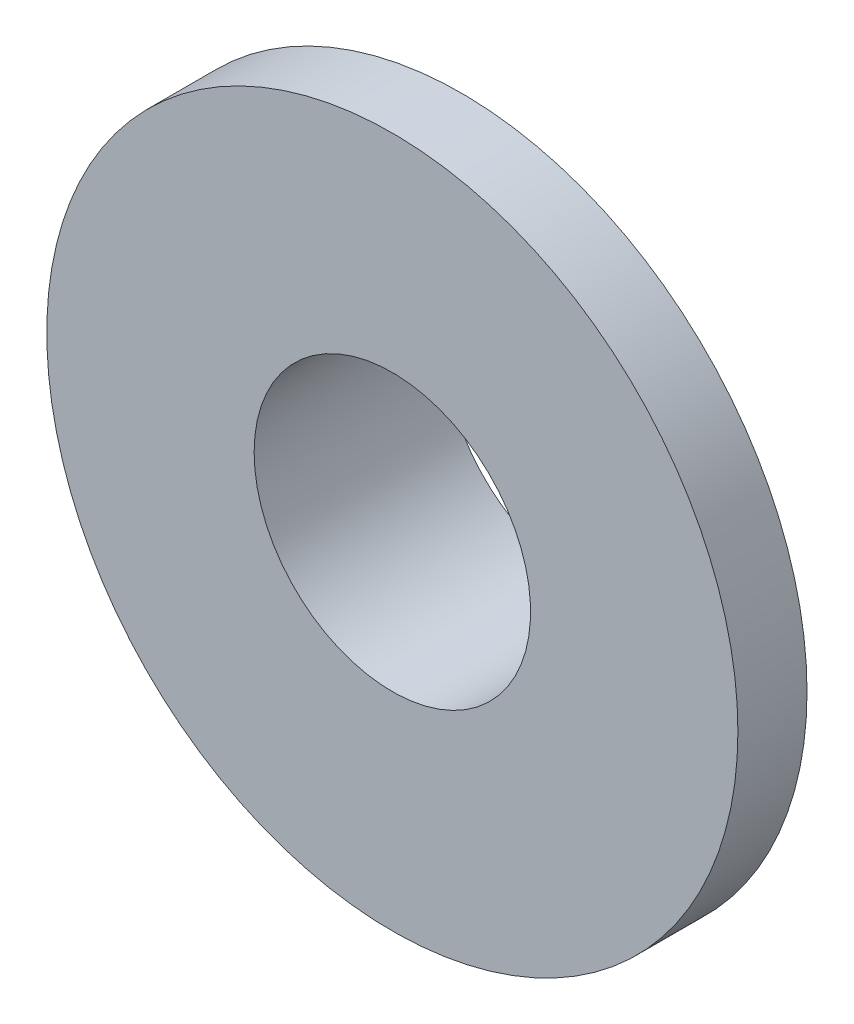
from build123d import *

# Parameters (mm, degrees)
SKETCH1_R           = 10
BOSS_EXTRUDE1_DEPTH = 2
SKETCH2_R           = 4.5
BOSS_EXTRUDE2_DEPTH = 3.5
SKETCH3_R           = 4
CUT_EXTRUDE1_DEPTH  = 6.5


with BuildPart() as part:
    # Sketch1 → Boss-Extrude1 (new body)
    with BuildSketch(Plane.XY):
        Circle(SKETCH1_R)
    extrude(amount=BOSS_EXTRUDE1_DEPTH)

    # Sketch2 → Boss-Extrude2 (add)
    with BuildSketch(Plane(origin=(0, 0, 0), x_dir=(-1, 0, 0), z_dir=(0, 0, -1))):
        Circle(SKETCH2_R)
    extrude(amount=BOSS_EXTRUDE2_DEPTH)

    # Sketch3 → Cut-Extrude1 (cut, through all)
    with BuildSketch(Plane(origin=(0, 0, -3.5), x_dir=(-1, 0, 0), z_dir=(0, 0, -1))):
        Circle(SKETCH3_R)
    extrude(amount=-CUT_EXTRUDE1_DEPTH, mode=Mode.SUBTRACT)


solid = part.part
